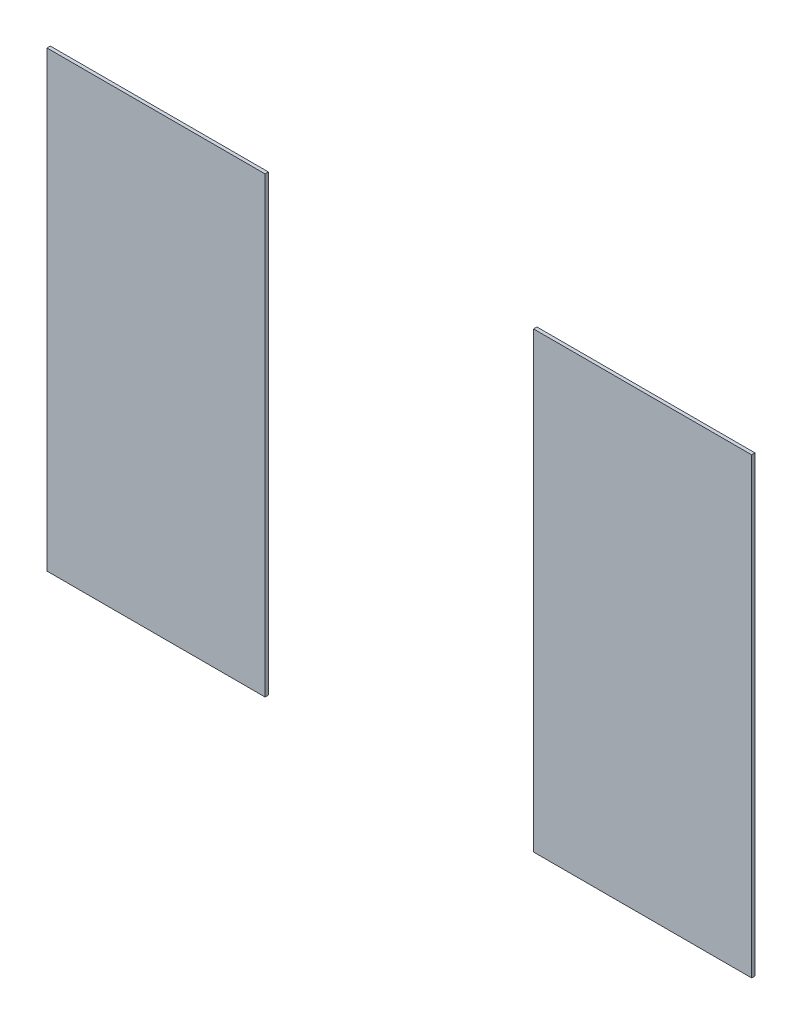
from build123d import *

# Parameters (mm, degrees)
SKETCH_1_W        = 1.3
SKETCH_1_H        = 2.7
EXTRUDE_1_DEPTH   = 0.02
EXTRUDE_1_2_DEPTH = 0.02


with BuildPart() as part:
    # 草图1 → 凸台-拉伸1 (new body)
    with BuildSketch(Plane.XY):
        with Locations((-1.45, 0)):
            Rectangle(SKETCH_1_W, SKETCH_1_H)
    extrude(amount=EXTRUDE_1_DEPTH)


with BuildPart() as body_2:
    # 草图1 → Extrude 1 2 (new body)
    with BuildSketch(Plane.XY):
        with Locations((1.45, 0)):
            Rectangle(SKETCH_1_W, SKETCH_1_H)
    extrude(amount=EXTRUDE_1_2_DEPTH)


solid = Compound([part.part, body_2.part])
